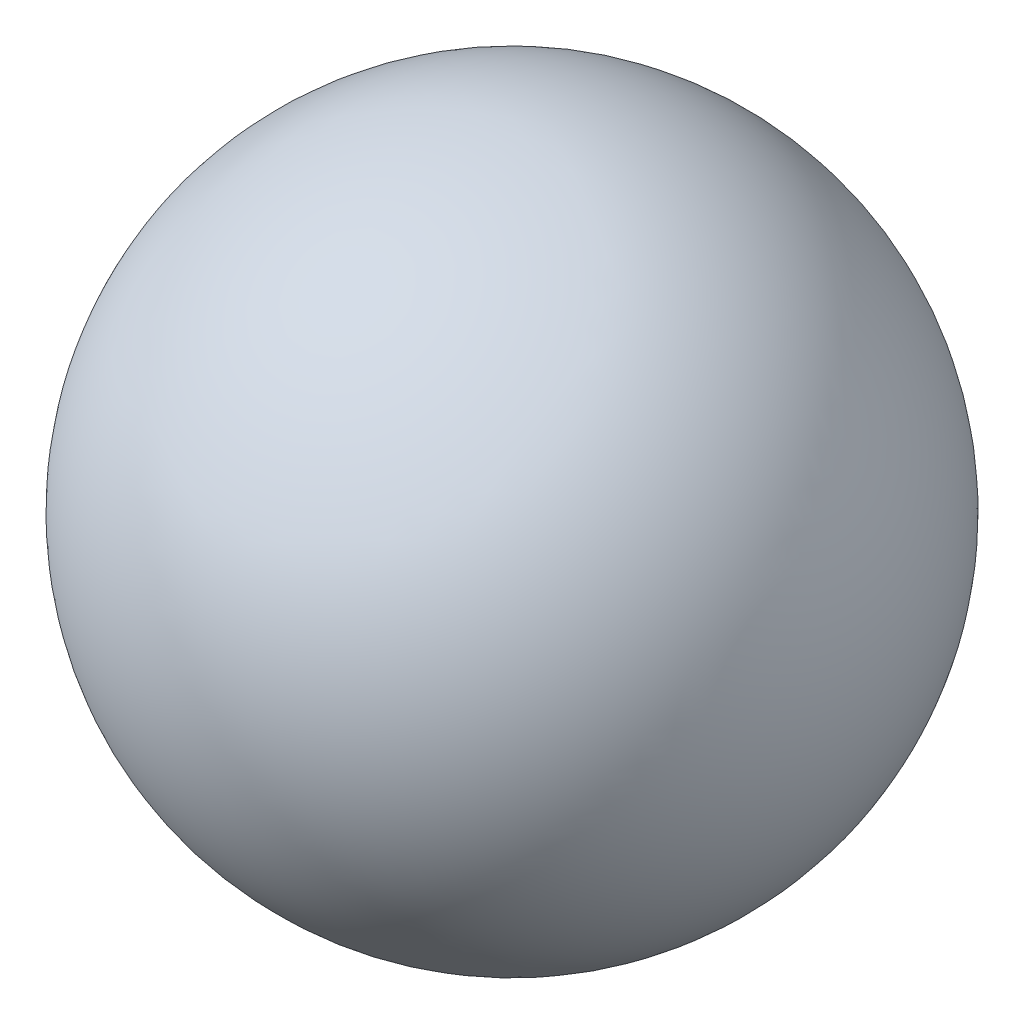
from build123d import *


with BuildPart() as part:
    # Sketch2 → Revolve3 (revolve)
    with BuildSketch(Plane(origin=(0, 0, 0), x_dir=(1, 0, 0), z_dir=(0, 1, 0))):
        with BuildLine():
            Line((-203.2, 0), (203.2, 0))
            ThreePointArc((203.2, 0), (0, 203.2), (-203.2, 0))
        make_face()
    revolve(axis=Axis((-203.2, 0, 0), (1, 0, 0)))


solid = part.part
